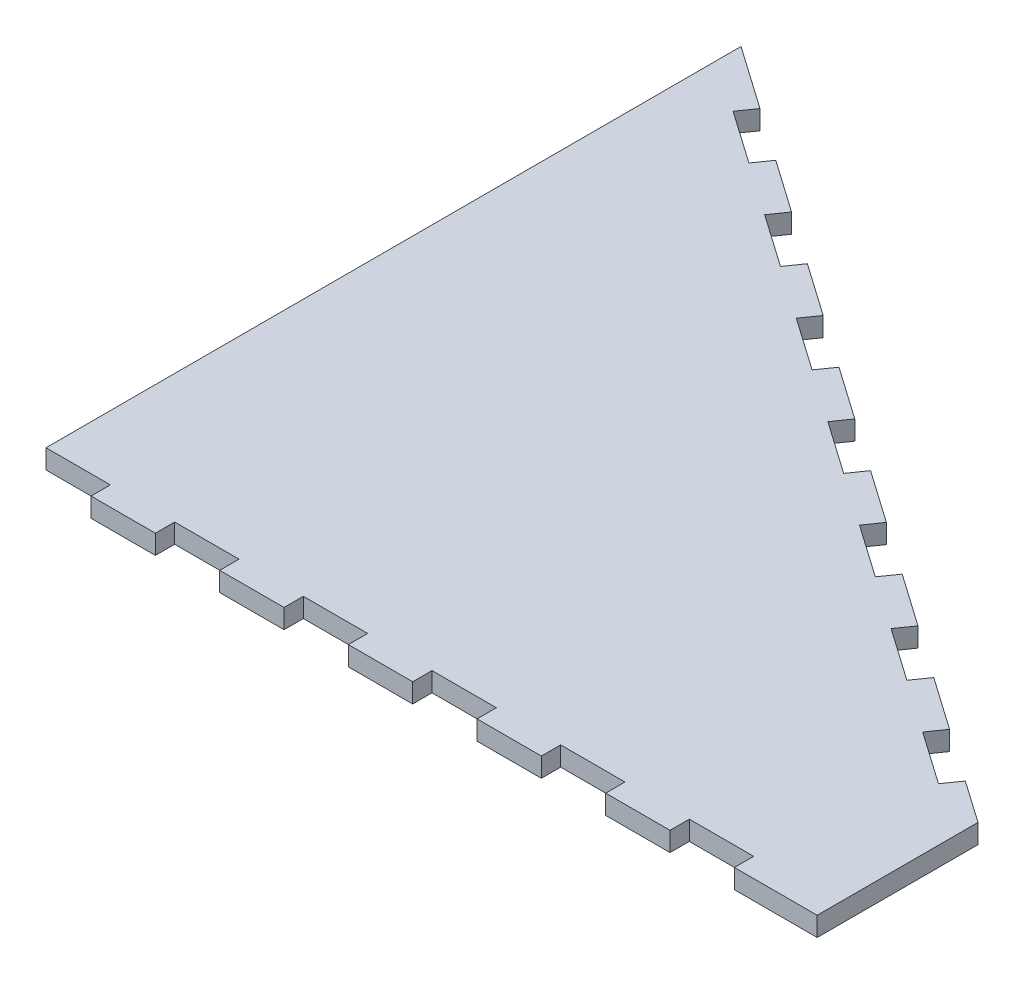
from build123d import *

# Parameters (mm, degrees)
BOSS_EXTRU_1_DEPTH = 3


with BuildPart() as part:
    # Esquisse1 → Boss.-Extru.1 (new body)
    with BuildSketch(Plane(origin=(0, 0, 0), x_dir=(1, 0, 0), z_dir=(0, 1, 0))):
        Polygon((0, 0), (0, 86.036465453), (9.829824531, 79.153548216), (8.109095222, 76.696092084), (16.300615665, 70.96032772), (18.021344974, 73.417783853), (26.212865417, 67.682019489), (24.492136108, 65.224563357), (32.683656551, 59.488798993), (34.40438586, 61.946255126), (42.595906303, 56.210490762), (40.875176994, 53.75303463), (49.066697437, 48.017270266), (50.787426746, 50.474726399), (58.978947189, 44.738962035), (57.25821788, 42.281505903), (65.449738323, 36.545741539), (67.170467632, 39.003197672), (75.361988075, 33.267433308), (73.641258766, 30.809977175), (81.832779208, 25.074212812), (83.553508517, 27.531668945), (91.74502896, 21.795904581), (90.024299651, 19.338448448), (98.215820094, 13.602684085), (99.936549403, 16.060140218), (108.128069846, 10.324375854), (106.407340537, 7.866919721), (114.59886098, 2.131155358), (116.319590289, 4.588611491), (122.872806643, 0), (122.872806643, -25), (110, -25), (110, -22), (100, -22), (100, -25), (90, -25), (90, -22), (80, -22), (80, -25), (70, -25), (70, -22), (60, -22), (60, -25), (50, -25), (50, -22), (40, -22), (40, -25), (30, -25), (30, -22), (20, -22), (20, -25), (10, -25), (10, -22), (0, -22), align=None)
    extrude(amount=BOSS_EXTRU_1_DEPTH)


solid = part.part
